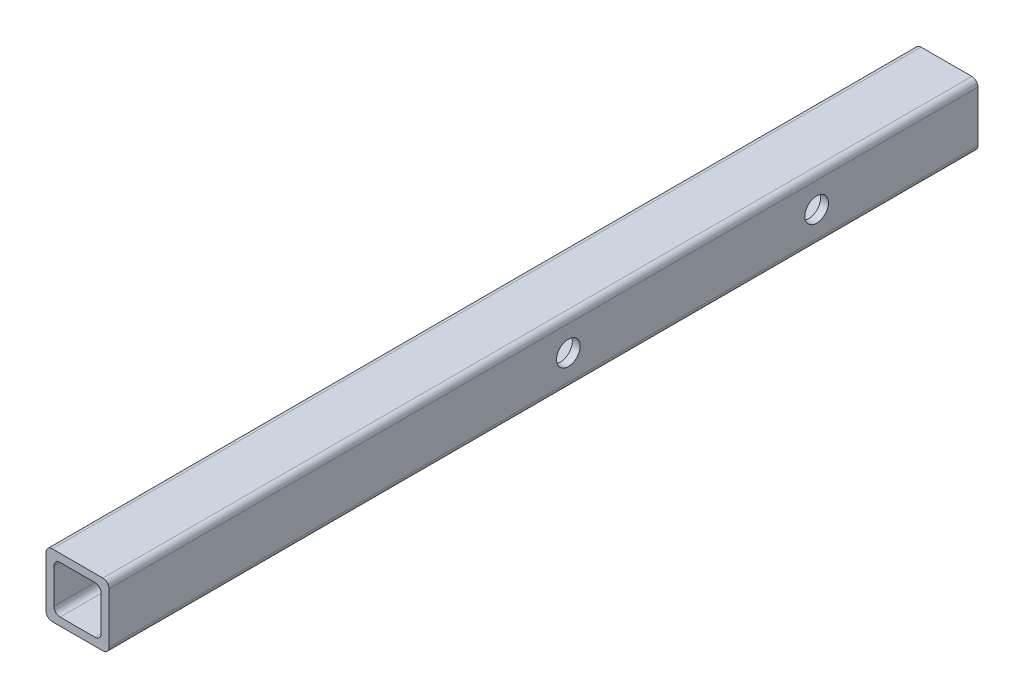
from build123d import *

# Parameters (mm, degrees)
SALIENTE_EXTRUIR1_DEPTH = 350
CROQUIS2_R              = 4.7625
CORTAR_EXTRUIR1_DEPTH   = 26.4


with BuildPart() as part:
    # Croquis1 → Saliente-Extruir1 (new body)
    with BuildSketch(Plane.XY):
        with BuildLine():
            Line((-10.2, -12.7), (10.2, -12.7))
            ThreePointArc((10.2, -12.7), (11.967766953, -11.967766953), (12.7, -10.2))
            Line((12.7, -10.2), (12.7, 10.2))
            ThreePointArc((12.7, 10.2), (11.967766953, 11.967766953), (10.2, 12.7))
            Line((10.2, 12.7), (-10.2, 12.7))
            ThreePointArc((-10.2, 12.7), (-11.967766953, 11.967766953), (-12.7, 10.2))
            Line((-12.7, 10.2), (-12.7, -10.2))
            ThreePointArc((-12.7, -10.2), (-11.967766953, -11.967766953), (-10.2, -12.7))
        make_face()
        with BuildLine():
            Line((-7.025, -9.525), (7.025, -9.525))
            ThreePointArc((7.025, -9.525), (8.792766953, -8.792766953), (9.525, -7.025))
            Line((9.525, -7.025), (9.525, 7.025))
            ThreePointArc((9.525, 7.025), (8.792766953, 8.792766953), (7.025, 9.525))
            Line((7.025, 9.525), (-7.025, 9.525))
            ThreePointArc((-7.025, 9.525), (-8.792766953, 8.792766953), (-9.525, 7.025))
            Line((-9.525, 7.025), (-9.525, -7.025))
            ThreePointArc((-9.525, -7.025), (-8.792766953, -8.792766953), (-7.025, -9.525))
        make_face(mode=Mode.SUBTRACT)
    extrude(amount=SALIENTE_EXTRUIR1_DEPTH)

    # Croquis2 → Cortar-Extruir1 (cut, through all)
    with BuildSketch(Plane.ZY.offset(12.7)):
        with Locations((65, 0)):
            Circle(CROQUIS2_R)
        with Locations((165, 0)):
            Circle(CROQUIS2_R)
    extrude(amount=-CORTAR_EXTRUIR1_DEPTH, mode=Mode.SUBTRACT)


solid = part.part
